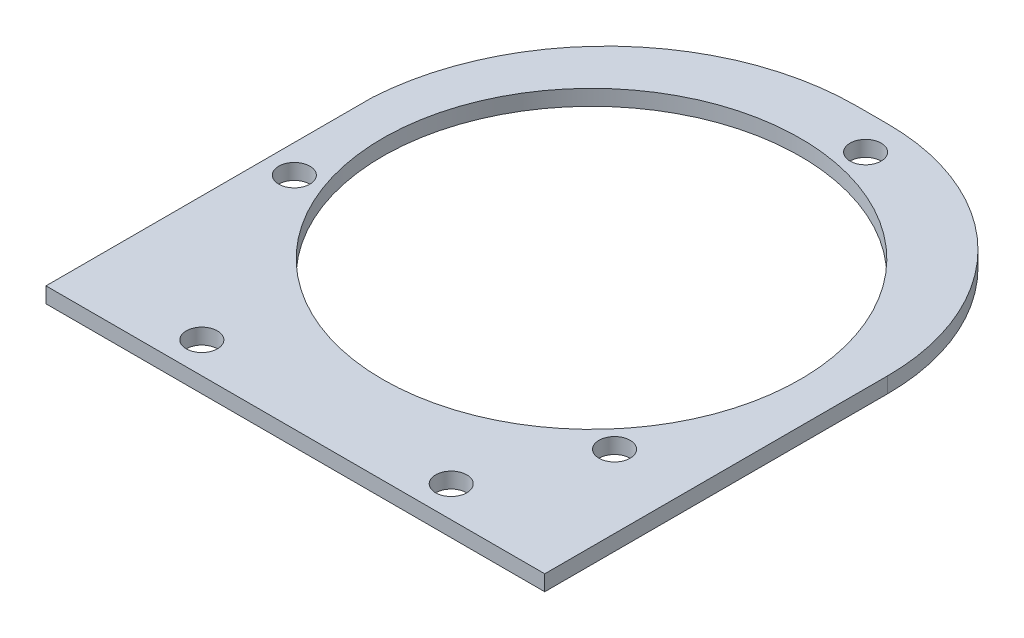
from build123d import *

# Parameters (mm, degrees)
SKETCH1_R           = 85.09
SKETCH1_R_2         = 6.35
BOSS_EXTRUDE1_DEPTH = 6.35


with BuildPart() as part:
    # Sketch1 → Boss-Extrude1 (new body)
    with BuildSketch(Plane(origin=(0, 0, 0), x_dir=(1, 0, 0), z_dir=(0, 1, 0))):
        with BuildLine():
            Line((12.7, 114.3), (0, 114.3))
            ThreePointArc((0, 114.3), (-69.761055355, 86.634356609), (-101.6, 18.676470588))
            Line((-101.6, 18.676470588), (-101.6, -114.3))
            Line((-101.6, -114.3), (101.6, -114.3))
            Line((101.6, -114.3), (101.6, 25.4))
            ThreePointArc((101.6, 25.4), (75.561792847, 88.261792847), (12.7, 114.3))
        make_face()
        with Locations((0, 6.35)):
            Circle(SKETCH1_R, mode=Mode.SUBTRACT)
        with Locations((-90.060644326, -24.660366712)):
            Circle(SKETCH1_R_2, mode=Mode.SUBTRACT)
        with Locations((-50.8, -101.6)):
            Circle(SKETCH1_R_2, mode=Mode.SUBTRACT)
        with Locations((50.8, -101.6)):
            Circle(SKETCH1_R_2, mode=Mode.SUBTRACT)
        with Locations((18.17455681, 99.849989223)):
            Circle(SKETCH1_R_2, mode=Mode.SUBTRACT)
        with Locations((71.886087516, -56.139622511)):
            Circle(SKETCH1_R_2, mode=Mode.SUBTRACT)
    extrude(amount=BOSS_EXTRUDE1_DEPTH)


solid = part.part
